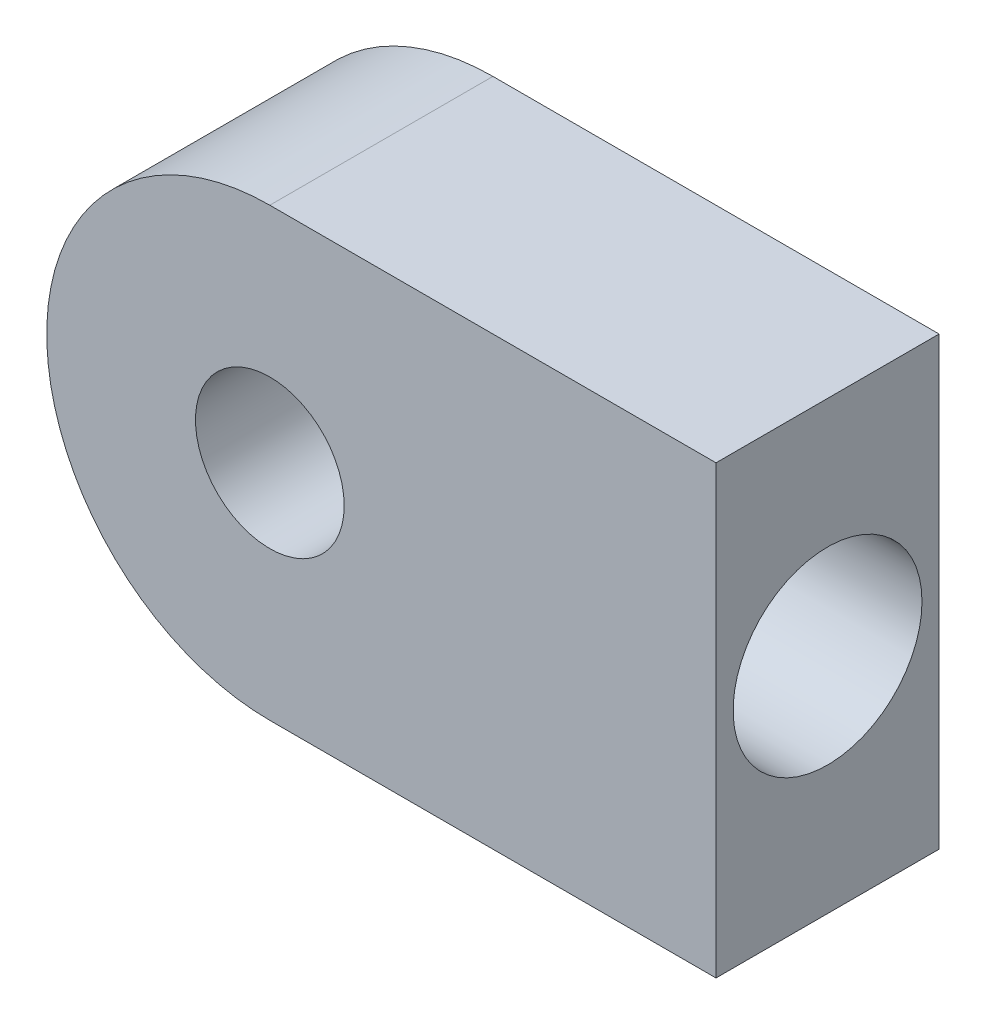
from build123d import *

# Parameters (mm, degrees)
SKETCH1_R           = 5
BOSS_EXTRUDE1_DEPTH = 7.5
SKETCH2_R           = 6.35
CUT_EXTRUDE1_DEPTH  = 20


with BuildPart() as part:
    # Sketch1 → Boss-Extrude1 (new body, symmetric)
    with BuildSketch(Plane.XY):
        with BuildLine():
            Line((0, 15), (30, 15))
            Line((30, 15), (30, -15))
            Line((30, -15), (0, -15))
            ThreePointArc((0, -15), (-15, 0), (0, 15))
        make_face()
        Circle(SKETCH1_R, mode=Mode.SUBTRACT)
    extrude(amount=BOSS_EXTRUDE1_DEPTH, both=True)

    # Sketch2 → Cut-Extrude1 (cut)
    with BuildSketch(Plane(origin=(30, 0, 0), x_dir=(0, 0, -1), z_dir=(1, 0, 0))):
        Circle(SKETCH2_R)
    extrude(amount=-CUT_EXTRUDE1_DEPTH, mode=Mode.SUBTRACT)


solid = part.part
